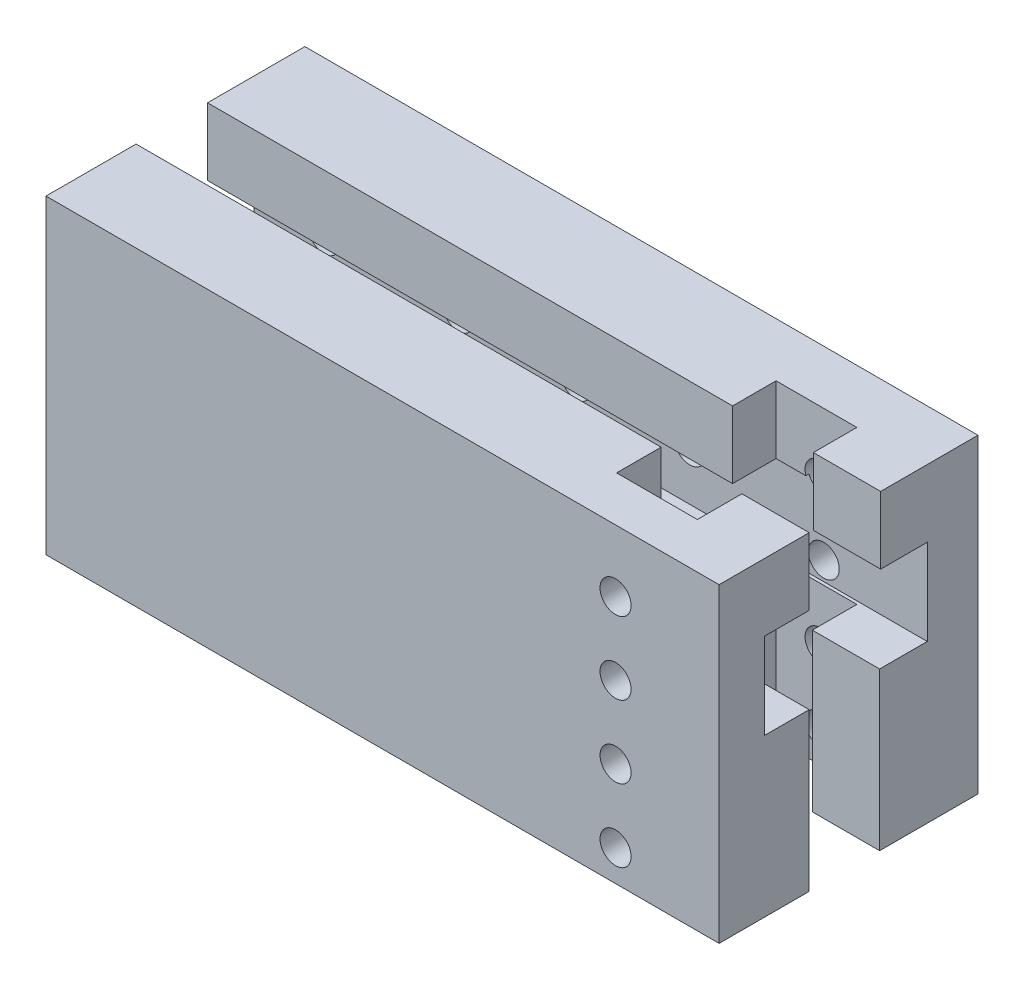
from build123d import *

# Parameters (mm, degrees)
SKETCH1_W           = 65
SKETCH1_H           = 30
BOSS_EXTRUDE1_DEPTH = 25
SKETCH2_W           = 6.5
SKETCH2_H           = 6.8
CUT_EXTRUDE1_DEPTH  = 31
SKETCH5_R           = 1.5
CUT_EXTRUDE3_DEPTH  = 26
SKETCH6_W           = 6.9
SKETCH6_H           = 6.5
CUT_EXTRUDE4_DEPTH  = 66
SKETCH7_R           = 1.5
CUT_EXTRUDE5_DEPTH  = 10


with BuildPart() as part:
    # Sketch1 → Boss-Extrude1 (new body)
    with BuildSketch(Plane.XY):
        with Locations((28.266423358, -11.605839416)):
            Rectangle(SKETCH1_W, SKETCH1_H)
    extrude(amount=BOSS_EXTRUDE1_DEPTH)

    # Sketch2 → Cut-Extrude1 (cut, through all)
    with BuildSketch(Plane(origin=(0, 3.394160584, 0), x_dir=(1, 0, 0), z_dir=(0, 1, 0))):
        with Locations((57.516423358, -12.9)):
            Rectangle(SKETCH2_W, SKETCH2_H)
        Polygon((54.266423358, -20.6), (54.266423358, -16.3), (54.266423358, -9.5), (54.266423358, -5.2), (46.466423358, -5.2), (46.466423358, -20.6), align=None)
    extrude(amount=-CUT_EXTRUDE1_DEPTH, mode=Mode.SUBTRACT)

    # Sketch5 → Cut-Extrude3 (cut, through all)
    with BuildSketch(Plane.XY.offset(25)):
        with Locations((50.766423358, -2.605839416)):
            Circle(SKETCH5_R)
        with Locations((50.766423358, -9.605839416)):
            Circle(SKETCH5_R)
        with Locations((50.766423358, -16.605839416)):
            Circle(SKETCH5_R)
        with Locations((50.766423358, -23.605839416)):
            Circle(SKETCH5_R)
    extrude(amount=-CUT_EXTRUDE3_DEPTH, mode=Mode.SUBTRACT)

    # Sketch6 → Cut-Extrude4 (cut, through all)
    with BuildSketch(Plane.ZY.offset(4.233576642)):
        Polygon((16.3, -3.105839416), (9.4, -3.105839416), (4.9, -3.105839416), (4.9, -11.405839416), (20.6, -11.405839416), (20.6, -3.105839416), align=None)
        with Locations((12.85, 0.144160584)):
            Rectangle(SKETCH6_W, SKETCH6_H)
    extrude(amount=-CUT_EXTRUDE4_DEPTH, mode=Mode.SUBTRACT)

    # Sketch7 → Cut-Extrude5 (cut)
    with BuildSketch(Plane(origin=(0, 0, 0), x_dir=(-1, 0, 0), z_dir=(0, 0, -1))):
        with Locations((-2.506646914, -6.605839416)):
            Circle(SKETCH7_R)
        with Locations((-15.4668355, -6.605839416)):
            Circle(SKETCH7_R)
        with Locations((-26.853051517, -6.605839416)):
            Circle(SKETCH7_R)
        with Locations((-37.836637843, -6.605839416)):
            Circle(SKETCH7_R)
    extrude(amount=-CUT_EXTRUDE5_DEPTH, mode=Mode.SUBTRACT)


solid = part.part
